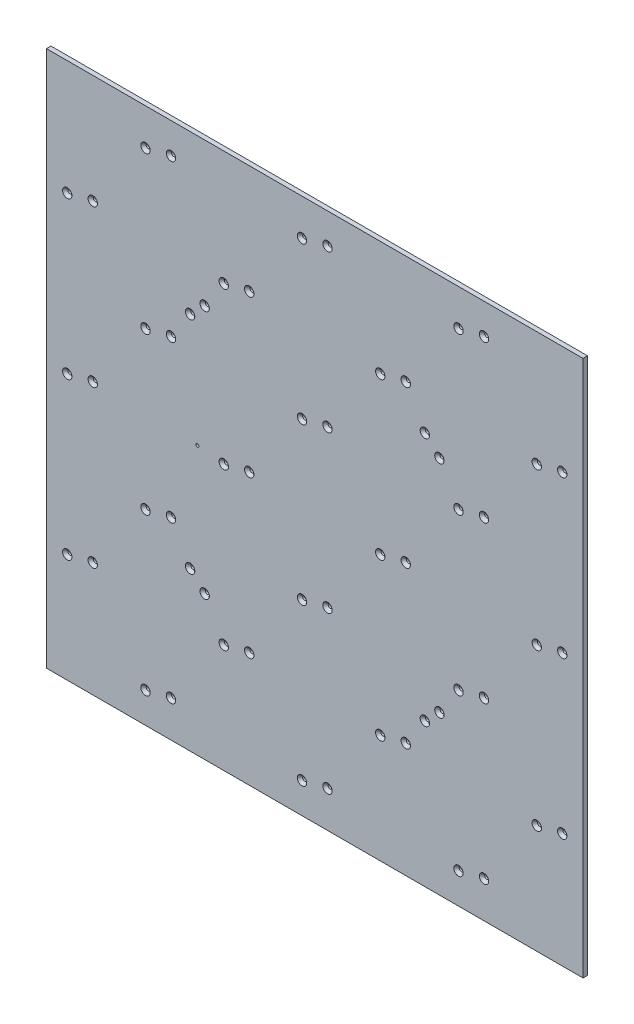
from build123d import *

# Parameters (mm, degrees)
BOSS_EXTRUDE1_START = 3
SKETCH1_W           = 1200
SKETCH1_H           = 1200
BOSS_EXTRUDE1_DEPTH = 10
SKETCH2_R           = 4.5
CUT_EXTRUDE1_DEPTH  = 11
CHAMFER1_SIZE       = 6
CUT_EXTRUDE2_REACH  = 12
SKETCH3_R           = 3.4


with BuildPart() as part:
    # Sketch1 → Boss-Extrude1 (new body)
    with BuildSketch(Plane.XY.offset(BOSS_EXTRUDE1_START)):
        Rectangle(SKETCH1_W, SKETCH1_H)
    extrude(amount=-BOSS_EXTRUDE1_DEPTH)

    # Sketch2 → Cut-Extrude1 (cut, through all)
    with BuildSketch(Plane(origin=(0, 0, -7), x_dir=(-1, 0, 0), z_dir=(0, 0, -1))):
        with Locations((246.236544033, -278.763455967)):
            Circle(SKETCH2_R)
        with Locations((278.763455967, -246.236544033)):
            Circle(SKETCH2_R)
        with Locations((-246.236544033, -278.763455967)):
            Circle(SKETCH2_R)
        with Locations((-278.763455967, -246.236544033)):
            Circle(SKETCH2_R)
        with Locations((-278.763455967, 246.236544033)):
            Circle(SKETCH2_R)
        with Locations((-246.236544033, 278.763455967)):
            Circle(SKETCH2_R)
        with Locations((278.763455967, 246.236544033)):
            Circle(SKETCH2_R)
        with Locations((246.236544033, 278.763455967)):
            Circle(SKETCH2_R)
        with Locations((378.500117834, -531.572378513)):
            Circle(SKETCH2_R)
        with Locations((321.50731127, -518.420192383)):
            Circle(SKETCH2_R)
        with Locations((553.501975109, -356.570521237)):
            Circle(SKETCH2_R)
        with Locations((496.509168546, -343.418335107)):
            Circle(SKETCH2_R)
        with Locations((28.496403282, -531.572378513)):
            Circle(SKETCH2_R)
        with Locations((-28.496403282, -518.420192383)):
            Circle(SKETCH2_R)
        with Locations((203.498260558, -356.570521237)):
            Circle(SKETCH2_R)
        with Locations((146.505453994, -343.418335107)):
            Circle(SKETCH2_R)
        with Locations((378.500117834, -181.568663962)):
            Circle(SKETCH2_R)
        with Locations((321.50731127, -168.416477832)):
            Circle(SKETCH2_R)
        with Locations((553.501975109, -6.566806686)):
            Circle(SKETCH2_R)
        with Locations((496.509168546, 6.585379444)):
            Circle(SKETCH2_R)
        with Locations((553.501975109, 343.436907866)):
            Circle(SKETCH2_R)
        with Locations((496.509168546, 356.589093996)):
            Circle(SKETCH2_R)
        with Locations((378.500117834, 518.438765142)):
            Circle(SKETCH2_R)
        with Locations((321.50731127, 531.590951272)):
            Circle(SKETCH2_R)
        with Locations((378.500117834, 168.43505059)):
            Circle(SKETCH2_R)
        with Locations((321.50731127, 181.58723672)):
            Circle(SKETCH2_R)
        with Locations((203.498260558, 343.436907866)):
            Circle(SKETCH2_R)
        with Locations((146.505453994, 356.589093996)):
            Circle(SKETCH2_R)
        with Locations((203.498260558, -6.566806686)):
            Circle(SKETCH2_R)
        with Locations((146.505453994, 6.585379444)):
            Circle(SKETCH2_R)
        with Locations((28.496403282, 168.43505059)):
            Circle(SKETCH2_R)
        with Locations((-28.496403282, 181.58723672)):
            Circle(SKETCH2_R)
        with Locations((28.496403282, -181.568663962)):
            Circle(SKETCH2_R)
        with Locations((-28.496403282, -168.416477832)):
            Circle(SKETCH2_R)
        with Locations((-146.505453994, -6.566806686)):
            Circle(SKETCH2_R)
        with Locations((-203.498260558, 6.585379444)):
            Circle(SKETCH2_R)
        with Locations((-146.505453994, -356.570521237)):
            Circle(SKETCH2_R)
        with Locations((-203.498260558, -343.418335107)):
            Circle(SKETCH2_R)
        with Locations((-321.50731127, -181.568663962)):
            Circle(SKETCH2_R)
        with Locations((-378.500117834, -168.416477832)):
            Circle(SKETCH2_R)
        with Locations((-553.501975109, -343.418335107)):
            Circle(SKETCH2_R)
        with Locations((-496.509168546, -356.570521237)):
            Circle(SKETCH2_R)
        with Locations((-378.500117834, -518.420192383)):
            Circle(SKETCH2_R)
        with Locations((-321.50731127, -531.572378513)):
            Circle(SKETCH2_R)
        with Locations((28.496403282, 518.438765142)):
            Circle(SKETCH2_R)
        with Locations((-28.496403282, 531.590951272)):
            Circle(SKETCH2_R)
        with Locations((-321.50731127, 518.438765142)):
            Circle(SKETCH2_R)
        with Locations((-378.500117834, 531.590951272)):
            Circle(SKETCH2_R)
        with Locations((-146.505453994, 343.436907866)):
            Circle(SKETCH2_R)
        with Locations((-203.498260558, 356.589093996)):
            Circle(SKETCH2_R)
        with Locations((-496.509168546, 343.436907866)):
            Circle(SKETCH2_R)
        with Locations((-553.501975109, 356.589093996)):
            Circle(SKETCH2_R)
        with Locations((-321.50731127, 168.43505059)):
            Circle(SKETCH2_R)
        with Locations((-378.500117834, 181.58723672)):
            Circle(SKETCH2_R)
        with Locations((-496.509168546, -6.566806686)):
            Circle(SKETCH2_R)
        with Locations((-553.501975109, 6.585379444)):
            Circle(SKETCH2_R)
    extrude(amount=-CUT_EXTRUDE1_DEPTH, mode=Mode.SUBTRACT)

    # Chamfer1
    chamfer1_edges = [part.edges().sort_by_distance(p)[0] for p in [
        (-549.001975109, 343.436907866, 3),
        (-492.009168546, 6.585379444, 3),
        (-549.001975109, -6.566806686, 3),
        (-317.00731127, -168.416477832, 3),
        (-142.005453994, 6.585379444, 3),
        (-23.996403282, 168.43505059, 3),
        (32.996403282, 181.58723672, 3),
        (-23.996403282, -181.568663962, 3),
        (-317.00731127, 181.58723672, 3),
        (-198.998260558, 343.436907866, 3),
        (-142.005453994, 356.589093996, 3),
        (-198.998260558, -6.566806686, 3),
        (250.736544033, 278.763455967, 3),
        (-274.263455967, 246.236544033, 3),
        (-241.736544033, 278.763455967, 3),
        (-374.000117834, -531.572378513, 3),
        (283.263455967, 246.236544033, 3),
        (283.263455967, -246.236544033, 3),
        (250.736544033, -278.763455967, 3),
        (-274.263455967, -246.236544033, 3),
        (-374.000117834, -181.568663962, 3),
        (-142.005453994, -343.418335107, 3),
        (-198.998260558, -356.570521237, 3),
        (32.996403282, -518.420192383, 3),
        (-317.00731127, -518.420192383, 3),
        (-549.001975109, -356.570521237, 3),
        (-492.009168546, -343.418335107, 3),
        (-23.996403282, -531.572378513, 3),
        (326.00731127, 168.43505059, 3),
        (558.001975109, 356.589093996, 3),
        (501.009168546, 343.436907866, 3),
        (207.998260558, 356.589093996, 3),
        (383.000117834, 181.58723672, 3),
        (501.009168546, -6.566806686, 3),
        (558.001975109, 6.585379444, 3),
        (558.001975109, -343.418335107, 3),
        (383.000117834, -168.416477832, 3),
        (326.00731127, -181.568663962, 3),
        (207.998260558, -343.418335107, 3),
        (32.996403282, -168.416477832, 3),
        (151.005453994, -6.566806686, 3),
        (207.998260558, 6.585379444, 3),
        (151.005453994, -356.570521237, 3),
        (32.996403282, 531.590951272, 3),
        (326.00731127, 518.438765142, 3),
        (383.000117834, 531.590951272, 3),
        (151.005453994, 343.436907866, 3),
        (-23.996403282, 518.438765142, 3),
        (326.00731127, -531.572378513, 3),
        (383.000117834, -518.420192383, 3),
        (501.009168546, -356.570521237, 3),
        (-241.736544033, -278.763455967, 3),
        (-492.009168546, 356.589093996, 3),
        (-374.000117834, 518.438765142, 3),
        (-317.00731127, 531.590951272, 3),
        (-374.000117834, 168.43505059, 3),
    ]]
    chamfer(chamfer1_edges, length=CHAMFER1_SIZE)

    # Sketch3 → Cut-Extrude2 (cut, up to next)
    with BuildSketch(Plane.XY.offset(3), mode=Mode.PRIVATE) as cut_extrude2_sk1:
        with Locations((-262.5, 0)):
            Circle(SKETCH3_R)
    cut_extrude2_tool1 = extrude(cut_extrude2_sk1.sketch, amount=-CUT_EXTRUDE2_REACH, mode=Mode.PRIVATE) & part.part
    add(cut_extrude2_tool1.solids().sort_by_distance((-262.5, 0, 3))[0], mode=Mode.SUBTRACT)


solid = part.part
